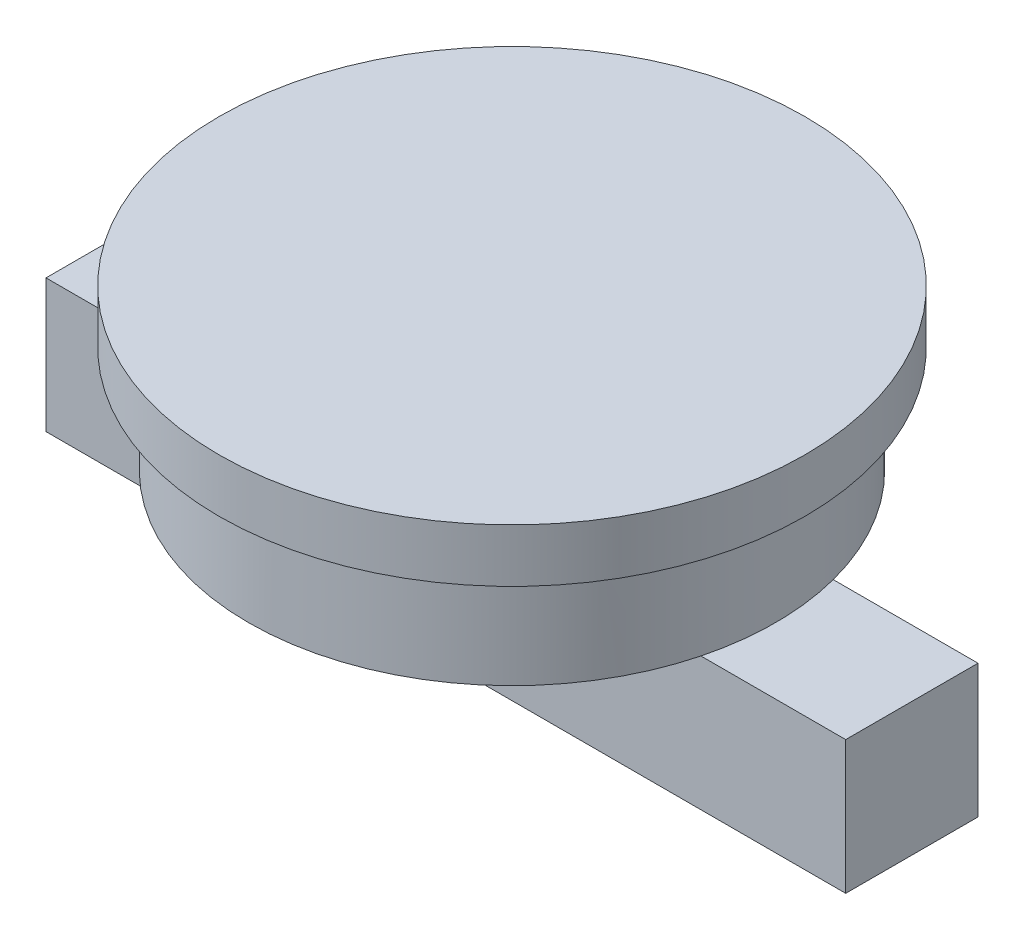
from build123d import *

# Parameters (mm, degrees)
SKETCH2_R           = 1100
BOSS_EXTRUDE1_DEPTH = 200
SKETCH3_R           = 989.441781837
BOSS_EXTRUDE2_DEPTH = 401
SKETCH4_W           = 3002.53007642
SKETCH4_H           = 496.680208904
BOSS_EXTRUDE3_DEPTH = 500


with BuildPart() as part:
    # Sketch2 → Boss-Extrude1 (new body)
    with BuildSketch(Plane(origin=(0, 0, 0), x_dir=(1, 0, 0), z_dir=(0, 1, 0))):
        Circle(SKETCH2_R)
    extrude(amount=-BOSS_EXTRUDE1_DEPTH)

    # Sketch3 → Boss-Extrude2 (add)
    with BuildSketch(Plane.XZ.offset(200)):
        Circle(SKETCH3_R)
    extrude(amount=BOSS_EXTRUDE2_DEPTH)

    # Sketch4 → Boss-Extrude3 (add)
    with BuildSketch(Plane.XZ.offset(601)):
        Rectangle(SKETCH4_W, SKETCH4_H)
    extrude(amount=BOSS_EXTRUDE3_DEPTH)


solid = part.part
